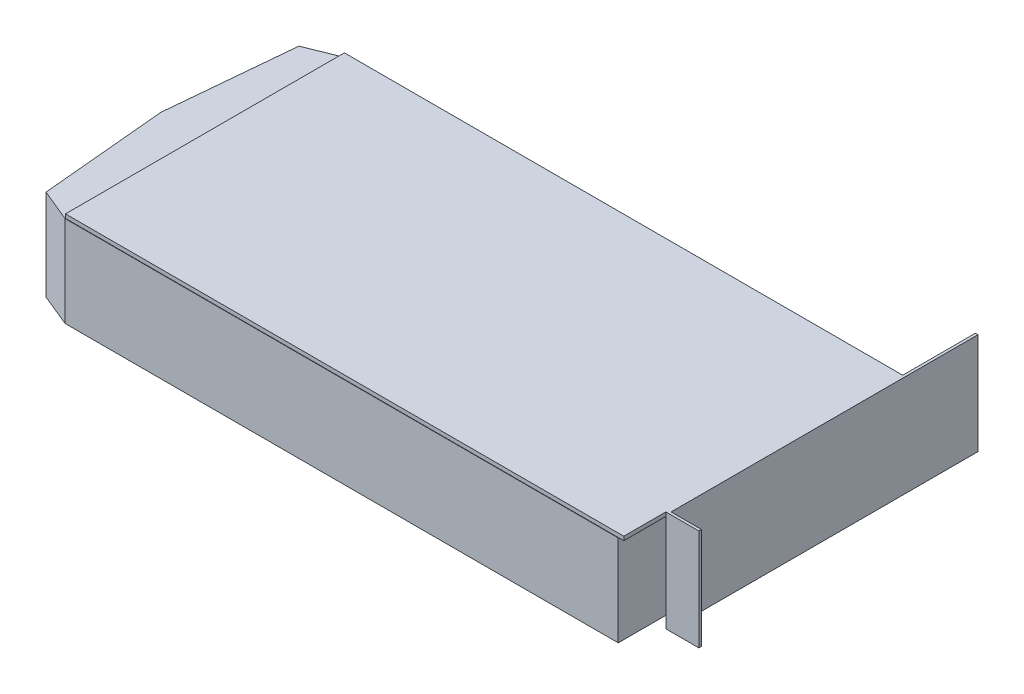
from build123d import *

# Parameters (mm, degrees)
CARD_W              = 215
CARD_H              = 107.4
BOSS_EXTRUDE1_DEPTH = 1.5
SKETCH2_W           = 119.2
SKETCH2_H           = 39
BOSS_EXTRUDE2_DEPTH = 1
SKETCH3_W           = 1
SKETCH3_H           = 39
BOSS_EXTRUDE3_DEPTH = 11.7
BOSS_EXTRUDE4_DEPTH = 35


with BuildPart() as part:
    # card → Boss-Extrude1 (new body)
    with BuildSketch(Plane(origin=(0, 0, 0), x_dir=(1, 0, 0), z_dir=(0, 1, 0))):
        with Locations((107.5, 53.7)):
            Rectangle(CARD_W, CARD_H)
    extrude(amount=BOSS_EXTRUDE1_DEPTH)

    # Sketch2 → Boss-Extrude2 (add)
    with BuildSketch(Plane(origin=(215, 0, 0), x_dir=(0, 0, -1), z_dir=(1, 0, 0))):
        with Locations((75.8, -18)):
            Rectangle(SKETCH2_W, SKETCH2_H)
    extrude(amount=BOSS_EXTRUDE2_DEPTH)

    # Sketch3 → Boss-Extrude3 (add)
    with BuildSketch(Plane(origin=(216, 0, 0), x_dir=(0, 0, -1), z_dir=(1, 0, 0))):
        with Locations((16.7, -18)):
            Rectangle(SKETCH3_W, SKETCH3_H)
    extrude(amount=BOSS_EXTRUDE3_DEPTH)

    # Sketch5 → Boss-Extrude4 (add)
    with BuildSketch(Plane.XZ):
        Polygon((213, 0), (213, -107.4), (0, -107.4), (-12.5, -102.4), (-17, -53.7), (-12.5, -5), (0, 0.14109814), (213, 0.14109814), align=None)
    extrude(amount=BOSS_EXTRUDE4_DEPTH)


solid = part.part
